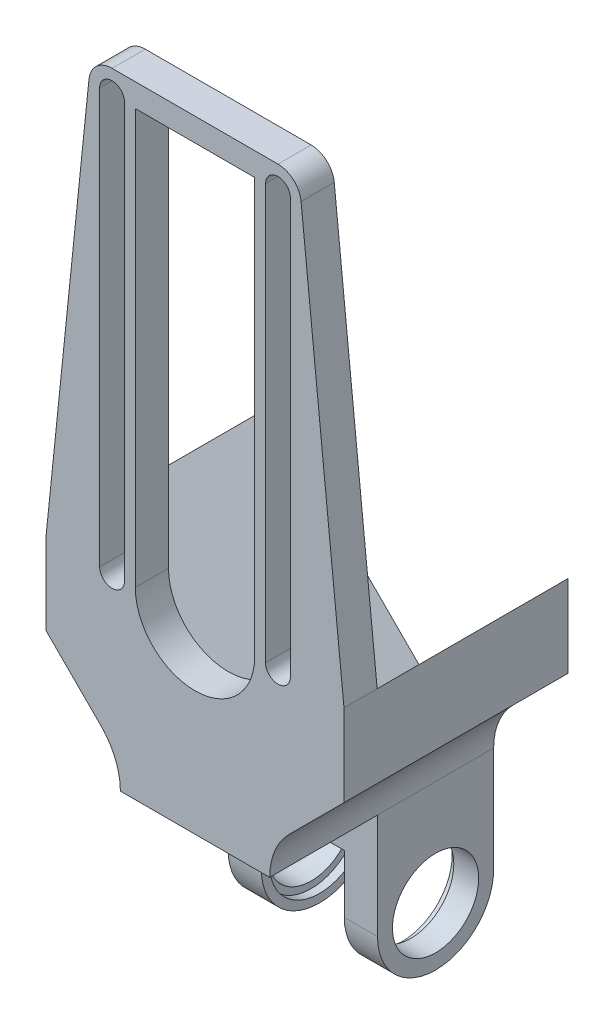
from build123d import *

# Parameters (mm, degrees)
SALIENTE_EXTRUIR1_START      = 9
CROQUIS1_R                   = 6
CROQUIS1_R_2                 = 5.2
SALIENTE_EXTRUIR1_DEPTH      = 3
SALIENTE_EXTRUIR2_START      = 9
CROQUIS1_3_R                 = 6
SALIENTE_EXTRUIR2_DEPTH      = 4
SALIENTE_EXTRUIR3_START      = -9
CROQUIS1_4_R                 = 7
CROQUIS1_4_R_2               = 6
SALIENTE_EXTRUIR3_DEPTH      = 4
SALIENTE_EXTRUIR4_START      = -9
CROQUIS1_5_R                 = 6
CROQUIS1_5_R_2               = 5.2
SALIENTE_EXTRUIR4_DEPTH      = 3
SALIENTE_EXTRUIR5_DEPTH      = 7
SALIENTE_EXTRUIR5_DEPTH_BACK = 7
CROQUIS3_R                   = 1.7
CORTAR_EXTRUIR1_DEPTH        = 7
CROQUIS4_R                   = 1.7
CORTAR_EXTRUIR2_DEPTH        = 7
CROQUIS5_R                   = 3.2
CORTAR_EXTRUIR3_DEPTH        = 3.4
CROQUIS6_R                   = 3.2
CORTAR_EXTRUIR4_DEPTH        = 3.4
REDONDEO1_R                  = 8
SALIENTE_EXTRUIR6_START      = 9
SALIENTE_EXTRUIR6_DEPTH      = 4
SALIENTE_EXTRUIR7_DEPTH      = 13


with BuildPart() as part:
    # Croquis1 → Saliente-Extruir1 (new body)
    with BuildSketch(Plane(origin=(0, 0, 0), x_dir=(0, 0, -1), z_dir=(1, 0, 0)).offset(SALIENTE_EXTRUIR1_START)):
        Circle(CROQUIS1_R)
        Circle(CROQUIS1_R_2, mode=Mode.SUBTRACT)
    extrude(amount=-SALIENTE_EXTRUIR1_DEPTH)

    # Croquis1_3 → Saliente-Extruir2 (add)
    with BuildSketch(Plane(origin=(0, 0, 0), x_dir=(0, 0, -1), z_dir=(1, 0, 0)).offset(SALIENTE_EXTRUIR2_START)):
        with BuildLine():
            Line((-7, 7), (-7, 0))
            ThreePointArc((-7, 0), (0, -7), (7, 0))
            Line((7, 0), (7, 7))
            Line((7, 7), (-7, 7))
        make_face()
        Circle(CROQUIS1_3_R, mode=Mode.SUBTRACT)
    extrude(amount=-SALIENTE_EXTRUIR2_DEPTH)



with BuildPart() as body_2:
    # Croquis1_4 → Saliente-Extruir3 (new body)
    with BuildSketch(Plane(origin=(0, 0, 0), x_dir=(0, 0, -1), z_dir=(1, 0, 0)).offset(SALIENTE_EXTRUIR3_START)):
        with BuildLine():
            Line((-7, 7), (-7, 0))
            ThreePointArc((-7, 0), (-4.949747468, 4.949747468), (0, 7))
            Line((0, 7), (-7, 7))
        make_face()
        with BuildLine():
            ThreePointArc((0, 7), (4.949747468, 4.949747468), (7, 0))
            Line((7, 0), (7, 7))
            Line((7, 7), (0, 7))
        make_face()
        Circle(CROQUIS1_4_R)
        Circle(CROQUIS1_4_R_2, mode=Mode.SUBTRACT)
    extrude(amount=SALIENTE_EXTRUIR3_DEPTH)

    # Croquis1_5 → Saliente-Extruir4 (add)
    with BuildSketch(Plane(origin=(0, 0, 0), x_dir=(0, 0, -1), z_dir=(1, 0, 0)).offset(SALIENTE_EXTRUIR4_START)):
        Circle(CROQUIS1_5_R)
        Circle(CROQUIS1_5_R_2, mode=Mode.SUBTRACT)
    extrude(amount=SALIENTE_EXTRUIR4_DEPTH)


with BuildPart() as part_1:
    add(part.part)

    add(body_2.part)  # Saliente-Extruir5 merges body 2
    # Croquis2 → Saliente-Extruir5 (add, two sides)
    with BuildSketch(Plane.XY) as saliente_extruir5_sk:
        Polygon((9, 16), (17.960512242, 24.960512242), (17.960512242, 34.860007179), (0, 16.899494937), (-17.960512242, 34.860007179), (-17.960512242, 24.960512242), (-9, 16), (-9, 7), (9, 7), align=None)
    extrude(amount=SALIENTE_EXTRUIR5_DEPTH)
    extrude(saliente_extruir5_sk.sketch, amount=-SALIENTE_EXTRUIR5_DEPTH_BACK)

    # Croquis3 → Cortar-Extruir1 (cut)
    with BuildSketch(Plane(origin=(8.449747468, 8.449747468, 0), x_dir=(0.7071067811865509, -0.7071067811865441, 0), z_dir=(0.7071067811865441, 0.7071067811865509, 0))):
        with Locations(Location((-24.649747468, 0, 0), (0, 0, 180))):
            Circle(CROQUIS3_R)
    extrude(amount=-CORTAR_EXTRUIR1_DEPTH, mode=Mode.SUBTRACT)

    # Croquis4 → Cortar-Extruir2 (cut)
    with BuildSketch(Plane(origin=(-8.449747468, 8.449747468, 0), x_dir=(0.7071067811865509, 0.7071067811865441, 0), z_dir=(-0.7071067811865441, 0.7071067811865509, 0))):
        with Locations(Location((24.649747468, 0, 0), (0, 0, 180))):
            Circle(CROQUIS4_R)
    extrude(amount=-CORTAR_EXTRUIR2_DEPTH, mode=Mode.SUBTRACT)

    # Croquis5 → Cortar-Extruir3 (cut)
    with BuildSketch(Plane(origin=(-3.5, 3.5, 0), x_dir=(-0.7071067811865511, -0.707106781186544, 0), z_dir=(0.707106781186544, -0.7071067811865511, 0))):
        with Locations(Location((-24.649747468, 0, 0), (0, 0, 180))):
            Circle(CROQUIS5_R)
    extrude(amount=-CORTAR_EXTRUIR3_DEPTH, mode=Mode.SUBTRACT)

    # Croquis6 → Cortar-Extruir4 (cut)
    with BuildSketch(Plane(origin=(3.5, 3.5, 0), x_dir=(-0.7071067811865512, 0.7071067811865438, 0), z_dir=(-0.7071067811865438, -0.7071067811865512, 0))):
        with Locations(Location((24.649747468, 0, 0), (0, 0, 180))):
            Circle(CROQUIS6_R)
    extrude(amount=-CORTAR_EXTRUIR4_DEPTH, mode=Mode.SUBTRACT)

    # Redondeo1
    redondeo1_edges = [part_1.edges().sort_by_distance(p)[0] for p in [
        (9, 16, 0),
        (-9, 16, 0),
    ]]
    fillet(redondeo1_edges, radius=REDONDEO1_R)



with BuildPart() as body_2_2:
    # Croquis7 → Saliente-Extruir6 (new body)
    with BuildSketch(Plane.XY.offset(7).offset(SALIENTE_EXTRUIR6_START)):
        with BuildLine():
            Line((-17.960512242, 34.860007179), (0, 16.899494937))
            Line((0, 16.899494937), (17.960512242, 34.860007179))
            Line((17.960512242, 34.860007179), (12.785288814, 85.146653693))
            ThreePointArc((12.785288814, 85.146653693), (12.796319785, 85.003519062), (12.8, 84.860007179))
            Line((12.8, 84.860007179), (12.8, 34.860007179))
            ThreePointArc((12.8, 34.860007179), (10, 32.060007179), (7.2, 34.860007179))
            ThreePointArc((7.2, 34.860007179), (0, 27.660007179), (-7.2, 34.860007179))
            ThreePointArc((-7.2, 34.860007179), (-10, 32.060007179), (-12.8, 34.860007179))
            Line((-12.8, 34.860007179), (-12.8, 84.860007179))
            ThreePointArc((-12.8, 84.860007179), (-12.796319785, 85.003519062), (-12.785288814, 85.146653693))
            Line((-12.785288814, 85.146653693), (-17.960512242, 34.860007179))
        make_face()
        with BuildLine():
            ThreePointArc((-12.8, 84.860007179), (-10, 87.660007179), (-7.2, 84.860007179))
            Line((-7.2, 84.860007179), (-7.2, 34.860007179))
            ThreePointArc((-7.2, 34.860007179), (-10, 32.060007179), (-12.8, 34.860007179))
            Line((-12.8, 34.860007179), (-12.8, 84.860007179))
        make_face()
        with BuildLine():
            Line((-11.5, 84.860007179), (-11.5, 34.860007179))
            ThreePointArc((-11.5, 34.860007179), (-10, 33.360007179), (-8.5, 34.860007179))
            Line((-8.5, 34.860007179), (-8.5, 84.860007179))
            ThreePointArc((-8.5, 84.860007179), (-10, 86.360007179), (-11.5, 84.860007179))
        make_face(mode=Mode.SUBTRACT)
        with BuildLine():
            Line((12.8, 84.860007179), (12.8, 34.860007179))
            ThreePointArc((12.8, 34.860007179), (10, 32.060007179), (7.2, 34.860007179))
            Line((7.2, 34.860007179), (7.2, 84.860007179))
            ThreePointArc((7.2, 84.860007179), (10, 87.660007179), (12.8, 84.860007179))
        make_face()
        with BuildLine():
            ThreePointArc((11.5, 84.860007179), (10, 86.360007179), (8.5, 84.860007179))
            Line((8.5, 84.860007179), (8.5, 34.860007179))
            ThreePointArc((8.5, 34.860007179), (10, 33.360007179), (11.5, 34.860007179))
            Line((11.5, 34.860007179), (11.5, 84.860007179))
        make_face(mode=Mode.SUBTRACT)
        with BuildLine():
            Line((0, 87.660007179), (-10, 87.660007179))
            ThreePointArc((-10, 87.660007179), (-8.020101013, 86.839906166), (-7.2, 84.860007179))
            Line((-7.2, 84.860007179), (0, 84.860007179))
            Line((0, 84.860007179), (0, 87.660007179))
        make_face()
        with BuildLine():
            ThreePointArc((7.2, 84.860007179), (8.020101013, 86.839906166), (10, 87.660007179))
            Line((10, 87.660007179), (0, 87.660007179))
            Line((0, 87.660007179), (0, 84.860007179))
            Line((0, 84.860007179), (7.2, 84.860007179))
        make_face()
    extrude(amount=SALIENTE_EXTRUIR6_DEPTH)


with BuildPart() as part_2:
    add(part_1.part)

    add(body_2_2.part)  # Saliente-Extruir7 merges body 2 2
    # Croquis7_4 → Saliente-Extruir7 (add)
    with BuildSketch(Plane.XY.offset(7)):
        with BuildLine():
            ThreePointArc((-9, 12.686291501), (-9.60896374, 15.74775896), (-11.343145751, 18.343145751))
            Line((-11.343145751, 18.343145751), (-17.960512242, 24.960512242))
            Line((-17.960512242, 24.960512242), (-17.960512242, 34.860007179))
            Line((-17.960512242, 34.860007179), (0, 16.899494937))
            Line((0, 16.899494937), (17.960512242, 34.860007179))
            Line((17.960512242, 34.860007179), (17.960512242, 24.960512242))
            Line((17.960512242, 24.960512242), (11.343145751, 18.343145751))
            ThreePointArc((11.343145751, 18.343145751), (9.60896374, 15.74775896), (9, 12.686291501))
            Line((9, 12.686291501), (-9, 12.686291501))
        make_face()
    extrude(amount=SALIENTE_EXTRUIR7_DEPTH)


solid = part_2.part
